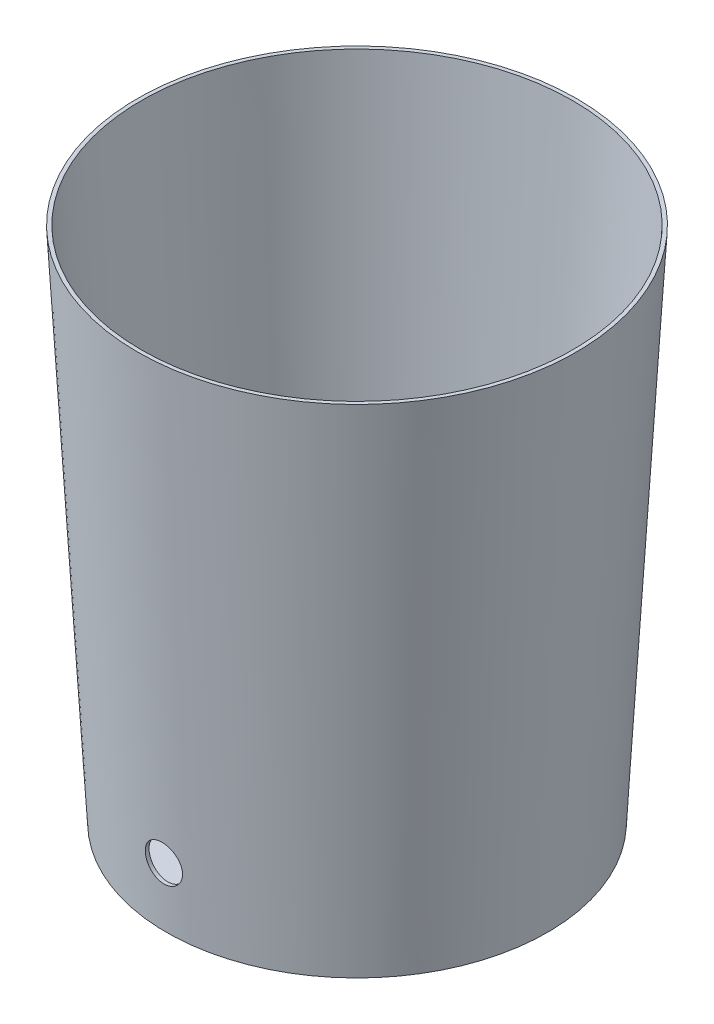
from build123d import *

# Parameters (mm, degrees)
SHELL1_T           = -2.54
CUT_EXTRUDE1_REACH = 151.86
SKETCH2_R          = 12.7


with BuildPart() as part:
    # Sketch1 → Revolve1 (revolve)
    with BuildSketch(Plane.XY):
        Polygon((0, 0), (0, 353.06), (149.86, 353.06), (130.048, 0), align=None)
    revolve(axis=Axis((0, 0, 0), (0, 1, 0)))

    # Shell1
    shell1_openings = [part.faces().sort_by_distance(p)[0] for p in [
        (0, 353.06, -149.86),
    ]]
    offset(amount=SHELL1_T, openings=shell1_openings, kind=Kind.INTERSECTION)

    # Sketch2 → Cut-Extrude1 (cut, up to next)
    with BuildSketch(Plane.XY, mode=Mode.PRIVATE) as cut_extrude1_sk1:
        with Locations((0, 42.17291268)):
            Circle(SKETCH2_R)
    cut_extrude1_tool1 = extrude(cut_extrude1_sk1.sketch, amount=CUT_EXTRUDE1_REACH, mode=Mode.PRIVATE) & part.part
    add(cut_extrude1_tool1.solids().sort_by_distance((0, 42.172913, 0))[0], mode=Mode.SUBTRACT)


solid = part.part
